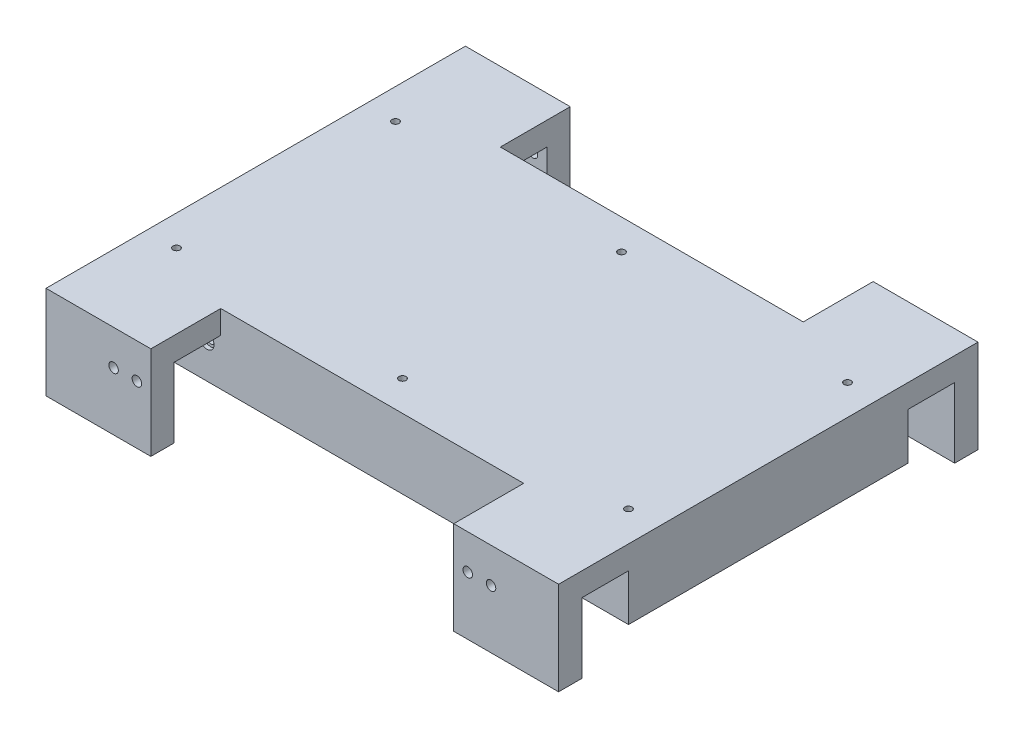
from build123d import *

# Parameters (mm, degrees)
SKETCH1_W                                      = 279.4
SKETCH1_H                                      = 152.4
SKETCH1_W_2                                    = 254
SKETCH1_H_2                                    = 127
EXTRUDE_THIN1_DEPTH                            = 50.8
SKETCH2_W                                      = 279.4
SKETCH2_H                                      = 152.4
BOSS_EXTRUDE2_DEPTH                            = 6.35
SKETCH13_W                                     = 64.77
SKETCH13_H                                     = 25.4
BOSS_EXTRUDE3_DEPTH                            = 31.75
BRAIN_SCREW_D                                  = 3.7973
BRAIN_SCREW_CBORE_D                            = 7.14502
BRAIN_SCREW_CBORE_DEPTH                        = 3.5052
SKETCH18_W                                     = 57.15
SKETCH18_H                                     = 50.8
AXEL_MOUNT_DEPTH                               = 38.1
SKETCH16_R                                     = 2.286
AXEL_THROUGH_DEPTH                             = 114.3
BRAN_SCREW_MIRROR_2_COPY_1_D                   = 3.7973
BRAN_SCREW_MIRROR_2_COPY_1_CBORE_D             = 7.14502
BRAN_SCREW_MIRROR_2_COPY_1_CBORE_DEPTH         = 3.5052
CBORE_FOR_6_SOCKET_HEAD_CAP_SCREW2_D           = 3.7973
CBORE_FOR_6_SOCKET_HEAD_CAP_SCREW2_CBORE_D     = 7.14502
CBORE_FOR_6_SOCKET_HEAD_CAP_SCREW2_CBORE_DEPTH = 3.5052
SKETCH19_W                                     = 25.4
SKETCH19_H                                     = 38.1
AXEL_CUTOUT_DEPTH                              = 303.043257838
MIRROR17_COPY_1_SKETCH_R                       = 2.286
MIRROR17_COPY_1_DEPTH                          = 114.3
MIRROR2_COPY_1_SKETCH_W                        = 57.15
MIRROR2_COPY_1_SKETCH_H                        = 50.8
MIRROR2_COPY_1_DEPTH                           = 38.1
MIRROR2_COPY_2_SKETCH_W                        = 25.4
MIRROR2_COPY_2_SKETCH_H                        = 38.1
MIRROR2_COPY_2_DEPTH                           = 303.043257838
SKETCH25_W                                     = 50.8
SKETCH25_H                                     = 25.4
MOTOR_CUTOUT_DEPTH                             = 10.414
SKETCH26_R                                     = 2.286
MOTOR_MOUNT_HOLES_DEPTH                        = 14.986
SKETCH37_W                                     = 2.5908
SKETCH37_H                                     = 50.8
F_6_0_204_DIAMETER_HOLE1_AT_2_COUNT            = 2
F_6_0_204_DIAMETER_HOLE1_AT_2_PITCH            = 12.7
MIRROR14_COPY_1_SKETCH_W                       = 2.5908
MIRROR14_COPY_1_SKETCH_H                       = 50.8
MIRROR15_COPY_1_SKETCH_W                       = 2.5908
MIRROR15_COPY_1_SKETCH_H                       = 50.8
MIRROR15_COPY_2_SKETCH_W                       = 2.5908
MIRROR15_COPY_2_SKETCH_H                       = 50.8
MIRROR15_COPY_3_SKETCH_W                       = 2.5908
MIRROR15_COPY_3_SKETCH_H                       = 50.8
MIRROR6_COPY_1_SKETCH_W                        = 50.8
MIRROR6_COPY_1_SKETCH_H                        = 25.4
MIRROR6_COPY_1_DEPTH                           = 10.414
MIRROR6_COPY_2_SKETCH_R                        = 2.286
MIRROR6_COPY_2_DEPTH                           = 14.986
COUNTERSINKMOTOR_MOUNT_AT_2_COUNT              = 2
COUNTERSINKMOTOR_MOUNT_AT_2_PITCH              = 12.7
SKETCH43_W                                     = 279.4
SKETCH43_H                                     = 152.4
CUT_EXTRUDE3_DEPTH                             = 19.05
AXEL_HOLES_DEPTH                               = 5.08
MIRROR30_COPY_1_DEPTH                          = 5.08


with BuildPart() as part:
    # Sketch1 → Extrude-Thin1 (new body)
    with BuildSketch(Plane(origin=(0, 0, 0), x_dir=(1, 0, 0), z_dir=(0, 1, 0))):
        with Locations((46.352288391, -14.803029666)):
            Rectangle(SKETCH1_W, SKETCH1_H)
        with Locations((46.352288391, -14.803029666)):
            Rectangle(SKETCH1_W_2, SKETCH1_H_2, mode=Mode.SUBTRACT)
    extrude(amount=EXTRUDE_THIN1_DEPTH)

    # Sketch2 → Boss-Extrude2 (add)
    with BuildSketch(Plane(origin=(0, 50.8, 0), x_dir=(1, 0, 0), z_dir=(0, 1, 0))):
        with Locations((46.352288391, -14.803029666)):
            Rectangle(SKETCH2_W, SKETCH2_H)
    extrude(amount=BOSS_EXTRUDE2_DEPTH)

    # Sketch13 → Boss-Extrude3 (add)
    with BuildSketch(Plane(origin=(0, 50.8, 0), x_dir=(-1, 0, 0), z_dir=(0, -1, 0))):
        with Locations((-140.967288391, -65.603029666)):
            Rectangle(SKETCH13_W, SKETCH13_H)
        with Locations((-140.967288391, 35.996970334)):
            Rectangle(SKETCH13_W, SKETCH13_H)
        with Locations((48.262711609, -65.603029666)):
            Rectangle(SKETCH13_W, SKETCH13_H)
        with Locations((48.262711609, 35.996970334)):
            Rectangle(SKETCH13_W, SKETCH13_H)
    extrude(amount=BOSS_EXTRUDE3_DEPTH)

    # Brain Screw (through all)
    with Locations(Plane(origin=(169.542288391, 19.05, -44.886970334), x_dir=(0, 0, -1), z_dir=(0, -1, 0))):
        with Locations((0, 0)):
            brain_screw = CounterBoreHole(BRAIN_SCREW_D / 2, BRAIN_SCREW_CBORE_D / 2, BRAIN_SCREW_CBORE_DEPTH)

    # Sketch18 → Axel Mount (add)
    with BuildSketch(Plane(origin=(0, 0, -61.396970334), x_dir=(-1, 0, 0), z_dir=(0, 0, -1))):
        with Locations((-157.477288391, 31.75)):
            Rectangle(SKETCH18_W, SKETCH18_H)
    axel_mount = extrude(amount=AXEL_MOUNT_DEPTH)

    # Sketch16 → Axel Through (cut)
    with BuildSketch(Plane(origin=(0, 0, -61.396970334), x_dir=(-1, 0, 0), z_dir=(0, 0, -1))):
        with Locations((-161.922288391, 38.1)):
            Circle(SKETCH16_R)
    axel_through = extrude(amount=-AXEL_THROUGH_DEPTH, mode=Mode.SUBTRACT)

    # Mirror16: Axel Through across plane
    add(axel_through.mirror(Plane.ZY.offset(-46.352288391)), mode=Mode.SUBTRACT)

    # Brain Screw Mirror: Brain Screw across plane
    add(brain_screw.mirror(Plane.ZY.offset(-46.352288391)), mode=Mode.SUBTRACT)

    # Bran Screw Mirror 2: Brain Screw across plane
    add(brain_screw.mirror(Plane.XY.offset(14.803029666)), mode=Mode.SUBTRACT)

    # Bran Screw Mirror 2 copy 1 (through all)
    with Locations(Plane(origin=(-76.837711609, 19.05, 74.493029666), x_dir=(0, 0, 1), z_dir=(0, -1, 0))):
        with Locations((0, 0)):
            CounterBoreHole(BRAN_SCREW_MIRROR_2_COPY_1_D / 2, BRAN_SCREW_MIRROR_2_COPY_1_CBORE_D / 2, BRAN_SCREW_MIRROR_2_COPY_1_CBORE_DEPTH)

    # CBORE for #6 Socket Head Cap Screw2 (through all)
    with Locations(Plane(origin=(46.352288391, 50.8, -44.886970334), x_dir=(0, 0, -1), z_dir=(0, -1, 0))):
        with Locations((0, 0)):
            cbore_for_6_socket_head_cap_screw2 = CounterBoreHole(CBORE_FOR_6_SOCKET_HEAD_CAP_SCREW2_D / 2, CBORE_FOR_6_SOCKET_HEAD_CAP_SCREW2_CBORE_D / 2, CBORE_FOR_6_SOCKET_HEAD_CAP_SCREW2_CBORE_DEPTH)

    # Mirror21: CBORE for #6 Socket Head Cap Screw2 across plane
    add(cbore_for_6_socket_head_cap_screw2.mirror(Plane.XY.offset(14.803029666)), mode=Mode.SUBTRACT)

    # Sketch19 → Axel Cutout (cut, through all)
    with BuildSketch(Plane(origin=(186.052288391, 0, 0), x_dir=(0, 0, -1), z_dir=(1, 0, 0))):
        with Locations((74.096970334, 25.4)):
            Rectangle(SKETCH19_W, SKETCH19_H)
    axel_cutout = extrude(amount=-AXEL_CUTOUT_DEPTH, mode=Mode.SUBTRACT)

    # Mirror17: Axel Through across plane
    add(axel_through.mirror(Plane.XY.offset(14.803029666)), mode=Mode.SUBTRACT)

    # Mirror17 copy 1 sketch → Mirror17 copy 1 (cut)
    with BuildSketch(Plane(origin=(92.704576782, 0, 91.003029666), x_dir=(1, 0, 0), z_dir=(0, 0, 1))):
        with Locations((-161.922288391, 38.1)):
            Circle(MIRROR17_COPY_1_SKETCH_R)
    extrude(amount=-MIRROR17_COPY_1_DEPTH, mode=Mode.SUBTRACT)

    # Mirror1: Axel Mount, Axel Cutout across plane
    add(axel_mount.mirror(Plane.ZY.offset(-46.352288391)))
    add(axel_cutout.mirror(Plane.ZY.offset(-46.352288391)), mode=Mode.SUBTRACT)

    # Mirror2: Axel Mount, Axel Cutout across plane
    add(axel_mount.mirror(Plane.XY.offset(14.803029666)))
    add(axel_cutout.mirror(Plane.XY.offset(14.803029666)), mode=Mode.SUBTRACT)

    # Mirror2 copy 1 sketch → Mirror2 copy 1 (add)
    with BuildSketch(Plane(origin=(92.704576782, 0, 91.003029666), x_dir=(1, 0, 0), z_dir=(0, 0, 1))):
        with Locations((-157.477288391, 31.75)):
            Rectangle(MIRROR2_COPY_1_SKETCH_W, MIRROR2_COPY_1_SKETCH_H)
    extrude(amount=MIRROR2_COPY_1_DEPTH)

    # Mirror2 copy 2 sketch → Mirror2 copy 2 (cut, through all)
    with BuildSketch(Plane(origin=(-93.347711609, 0, 29.606059332), x_dir=(0, 0, 1), z_dir=(-1, 0, 0))):
        with Locations((74.096970334, 25.4)):
            Rectangle(MIRROR2_COPY_2_SKETCH_W, MIRROR2_COPY_2_SKETCH_H)
    extrude(amount=-MIRROR2_COPY_2_DEPTH, mode=Mode.SUBTRACT)

    # Sketch25 → Motor Cutout (cut)
    with BuildSketch(Plane.XY.offset(-23.296970334)):
        with Locations((147.952288391, 38.1)):
            Rectangle(SKETCH25_W, SKETCH25_H)
    motor_cutout = extrude(amount=-MOTOR_CUTOUT_DEPTH, mode=Mode.SUBTRACT)

    # Sketch26 → Motor Mount Holes (cut)
    with BuildSketch(Plane.XY.offset(-33.710970334)):
        with Locations(Location((161.922288391, 38.1, 0), (0, 0, 180))):
            Circle(SKETCH26_R)
        with BuildLine():
            Line((141.99659531, 37.458182422), (141.545948431, 37.458182422))
            ThreePointArc((141.545948431, 37.458182422), (131.458921261, 38.091103702), (141.545948431, 38.724024983))
            Line((141.545948431, 38.724024983), (141.99659531, 38.724024983))
            Line((141.99659531, 38.724024983), (142.038169696, 40.095312833))
            Line((142.038169696, 40.095312833), (143.789562089, 40.095312833))
            Line((143.789562089, 40.095312833), (143.747987703, 38.724024983))
            Line((143.747987703, 38.724024983), (144.198634582, 38.724024983))
            ThreePointArc((144.198634582, 38.724024983), (154.285661752, 38.091103702), (144.198634582, 37.458182422))
            Line((144.198634582, 37.458182422), (143.747987703, 37.458182422))
            Line((143.747987703, 37.458182422), (143.706413317, 36.086894572))
            Line((143.706413317, 36.086894572), (141.955020924, 36.086894572))
            Line((141.955020924, 36.086894572), (141.99659531, 37.458182422))
        make_face()
    motor_mount_holes = extrude(amount=-MOTOR_MOUNT_HOLES_DEPTH, mode=Mode.SUBTRACT)

    # Sketch37 → #6 (0.204) Diameter Hole1 (revolve, cut)
    with BuildSketch(Plane(origin=(149.222291507, 38.091103702, -48.696970334), x_dir=(0, -1, 0), z_dir=(1, 0, 0))):
        with Locations((1.2954, 25.4)):
            Rectangle(SKETCH37_W, SKETCH37_H)
    f_6_0_204_diameter_hole1 = revolve(axis=Axis((149.222291507, 38.091103702, -42.346970334), (0, 0, -1)), mode=Mode.SUBTRACT)

    # #6 (0.204) Diameter Hole1 at 2: #6 (0.204) Diameter Hole1 ×2
    with Locations(*[(-i * F_6_0_204_DIAMETER_HOLE1_AT_2_PITCH, 0, 0) for i in range(1, F_6_0_204_DIAMETER_HOLE1_AT_2_COUNT)]):
        add(f_6_0_204_diameter_hole1, mode=Mode.SUBTRACT)

    # Mirror14: #6 (0.204) Diameter Hole1 across plane
    add(f_6_0_204_diameter_hole1.mirror(Plane.ZY.offset(-46.352288391)), mode=Mode.SUBTRACT)

    # Mirror14 copy 1 sketch → Mirror14 copy 1 (revolve, cut)
    with BuildSketch(Plane(origin=(-43.817714725, 38.091103702, -48.696970334), x_dir=(0, -1, 0), z_dir=(-1, 0, 0))):
        with Locations((1.2954, -25.4)):
            Rectangle(MIRROR14_COPY_1_SKETCH_W, MIRROR14_COPY_1_SKETCH_H)
    revolve(axis=Axis((-43.817714725, 38.091103702, -42.346970334), (0, 0, 1)), mode=Mode.SUBTRACT)

    # Mirror15: #6 (0.204) Diameter Hole1 across plane
    add(f_6_0_204_diameter_hole1.mirror(Plane.XY.offset(14.803029666)), mode=Mode.SUBTRACT)

    # Mirror15 copy 1 sketch → Mirror15 copy 1 (revolve, cut)
    with BuildSketch(Plane(origin=(136.522291507, 38.091103702, 78.303029666), x_dir=(0, -1, 0), z_dir=(1, 0, 0))):
        with Locations((1.2954, -25.4)):
            Rectangle(MIRROR15_COPY_1_SKETCH_W, MIRROR15_COPY_1_SKETCH_H)
    revolve(axis=Axis((136.522291507, 38.091103702, 71.953029666), (0, 0, -1)), mode=Mode.SUBTRACT)

    # Mirror15 copy 2 sketch → Mirror15 copy 2 (revolve, cut)
    with BuildSketch(Plane(origin=(-56.517714725, 38.091103702, 78.303029666), x_dir=(0, -1, 0), z_dir=(-1, 0, 0))):
        with Locations((1.2954, 25.4)):
            Rectangle(MIRROR15_COPY_2_SKETCH_W, MIRROR15_COPY_2_SKETCH_H)
    revolve(axis=Axis((-56.517714725, 38.091103702, 71.953029666), (0, 0, 1)), mode=Mode.SUBTRACT)

    # Mirror15 copy 3 sketch → Mirror15 copy 3 (revolve, cut)
    with BuildSketch(Plane(origin=(-43.817714725, 38.091103702, 78.303029666), x_dir=(0, -1, 0), z_dir=(-1, 0, 0))):
        with Locations((1.2954, 25.4)):
            Rectangle(MIRROR15_COPY_3_SKETCH_W, MIRROR15_COPY_3_SKETCH_H)
    revolve(axis=Axis((-43.817714725, 38.091103702, 71.953029666), (0, 0, 1)), mode=Mode.SUBTRACT)

    # Motor Cutout Mirror: Motor Cutout, Motor Mount Holes across plane
    add(motor_cutout.mirror(Plane.XY.offset(14.803029666)), mode=Mode.SUBTRACT)
    add(motor_mount_holes.mirror(Plane.XY.offset(14.803029666)), mode=Mode.SUBTRACT)

    # Mirror6: Motor Cutout, Motor Mount Holes across plane
    add(motor_cutout.mirror(Plane.ZY.offset(-46.352288391)), mode=Mode.SUBTRACT)
    add(motor_mount_holes.mirror(Plane.ZY.offset(-46.352288391)), mode=Mode.SUBTRACT)

    # Mirror6 copy 1 sketch → Mirror6 copy 1 (cut)
    with BuildSketch(Plane(origin=(92.704576782, 0, 52.903029666), x_dir=(-1, 0, 0), z_dir=(0, 0, -1))):
        with Locations((147.952288391, 38.1)):
            Rectangle(MIRROR6_COPY_1_SKETCH_W, MIRROR6_COPY_1_SKETCH_H)
    extrude(amount=-MIRROR6_COPY_1_DEPTH, mode=Mode.SUBTRACT)

    # Mirror6 copy 2 sketch → Mirror6 copy 2 (cut)
    with BuildSketch(Plane(origin=(92.704576782, 0, 63.317029666), x_dir=(-1, 0, 0), z_dir=(0, 0, -1))):
        with Locations(Location((161.922288391, 38.1, 0), (0, 0, 180))):
            Circle(MIRROR6_COPY_2_SKETCH_R)
        with BuildLine():
            Line((141.99659531, 37.458182422), (141.545948431, 37.458182422))
            ThreePointArc((141.545948431, 37.458182422), (131.458921261, 38.091103702), (141.545948431, 38.724024983))
            Line((141.545948431, 38.724024983), (141.99659531, 38.724024983))
            Line((141.99659531, 38.724024983), (142.038169696, 40.095312833))
            Line((142.038169696, 40.095312833), (143.789562089, 40.095312833))
            Line((143.789562089, 40.095312833), (143.747987703, 38.724024983))
            Line((143.747987703, 38.724024983), (144.198634582, 38.724024983))
            ThreePointArc((144.198634582, 38.724024983), (154.285661752, 38.091103702), (144.198634582, 37.458182422))
            Line((144.198634582, 37.458182422), (143.747987703, 37.458182422))
            Line((143.747987703, 37.458182422), (143.706413317, 36.086894572))
            Line((143.706413317, 36.086894572), (141.955020924, 36.086894572))
            Line((141.955020924, 36.086894572), (141.99659531, 37.458182422))
        make_face()
    extrude(amount=-MIRROR6_COPY_2_DEPTH, mode=Mode.SUBTRACT)

    # Sketch31 → CounterSinkMotor Mount (revolve, cut)
    with BuildSketch(Plane(origin=(136.522291507, 38.091103702, -61.396970334), x_dir=(0, 1, 0), z_dir=(1, 0, 0))):
        Polygon((0, 0), (0, 190.5), (1.89865, 190.5), (1.89865, 2.2098), (3.96875, 2.2098), (3.96875, 0), align=None)
    countersinkmotor_mount = revolve(axis=Axis((136.522291507, 38.091103702, -67.746970334), (0, 0, 1)), mode=Mode.SUBTRACT)

    # CounterSinkMotor Mount at 2: CounterSinkMotor Mount ×2
    with Locations(*[(i * COUNTERSINKMOTOR_MOUNT_AT_2_PITCH, 0, 0) for i in range(1, COUNTERSINKMOTOR_MOUNT_AT_2_COUNT)]):
        add(countersinkmotor_mount, mode=Mode.SUBTRACT)

    # Mirror9: CounterSinkMotor Mount across plane
    add(countersinkmotor_mount.mirror(Plane.XY.offset(14.803029666)), mode=Mode.SUBTRACT)

    # Mirror9 copy 1 sketch → Mirror9 copy 1 (revolve, cut)
    with BuildSketch(Plane(origin=(149.222291507, 38.091103702, 91.003029666), x_dir=(0, 1, 0), z_dir=(1, 0, 0))):
        Polygon((0, 0), (0, -190.5), (1.89865, -190.5), (1.89865, -2.2098), (3.96875, -2.2098), (3.96875, 0), align=None)
    revolve(axis=Axis((149.222291507, 38.091103702, 97.353029666), (0, 0, 1)), mode=Mode.SUBTRACT)

    # Mirror10: CounterSinkMotor Mount across plane
    add(countersinkmotor_mount.mirror(Plane.ZY.offset(-46.352288391)), mode=Mode.SUBTRACT)

    # Mirror10 copy 1 sketch → Mirror10 copy 1 (revolve, cut)
    with BuildSketch(Plane(origin=(-56.517714725, 38.091103702, -61.396970334), x_dir=(0, 1, 0), z_dir=(-1, 0, 0))):
        Polygon((0, 0), (0, -190.5), (1.89865, -190.5), (1.89865, -2.2098), (3.96875, -2.2098), (3.96875, 0), align=None)
    revolve(axis=Axis((-56.517714725, 38.091103702, -67.746970334), (0, 0, -1)), mode=Mode.SUBTRACT)

    # Mirror10 copy 2 sketch → Mirror10 copy 2 (revolve, cut)
    with BuildSketch(Plane(origin=(-43.817714725, 38.091103702, 91.003029666), x_dir=(0, 1, 0), z_dir=(-1, 0, 0))):
        Polygon((0, 0), (0, 190.5), (1.89865, 190.5), (1.89865, 2.2098), (3.96875, 2.2098), (3.96875, 0), align=None)
    revolve(axis=Axis((-43.817714725, 38.091103702, 97.353029666), (0, 0, -1)), mode=Mode.SUBTRACT)

    # Mirror10 copy 3 sketch → Mirror10 copy 3 (revolve, cut)
    with BuildSketch(Plane(origin=(-56.517714725, 38.091103702, 91.003029666), x_dir=(0, 1, 0), z_dir=(-1, 0, 0))):
        Polygon((0, 0), (0, 190.5), (1.89865, 190.5), (1.89865, 2.2098), (3.96875, 2.2098), (3.96875, 0), align=None)
    revolve(axis=Axis((-56.517714725, 38.091103702, 97.353029666), (0, 0, -1)), mode=Mode.SUBTRACT)

    # Sketch43 → Cut-Extrude3 (cut)
    with BuildSketch(Plane.XZ):
        with Locations((46.352288391, 14.803029666)):
            Rectangle(SKETCH43_W, SKETCH43_H)
    extrude(amount=-CUT_EXTRUDE3_DEPTH, mode=Mode.SUBTRACT)

    # Sketch44 → Axel Holes (cut)
    with BuildSketch(Plane.XY.offset(-86.796970334)):
        with BuildLine():
            Line((-64.869009253, 40.96385), (-50.899009253, 19.750667778))
            ThreePointArc((-50.899009253, 19.750667778), (-52.383861609, 12.538115422), (-59.596413965, 14.022967778))
            Line((-59.596413965, 14.022967778), (-73.566413965, 35.23615))
            ThreePointArc((-73.566413965, 35.23615), (-72.081561609, 42.448702356), (-64.869009253, 40.96385))
        make_face()
    axel_holes = extrude(amount=-AXEL_HOLES_DEPTH, mode=Mode.SUBTRACT)

    # Mirror29: Axel Holes across plane
    add(axel_holes.mirror(Plane.ZY.offset(-46.352288391)), mode=Mode.SUBTRACT)

    # Mirror30: Axel Holes across plane
    add(axel_holes.mirror(Plane.XY.offset(14.803029666)), mode=Mode.SUBTRACT)

    # Mirror30 copy 1 sketch → Mirror30 copy 1 (cut)
    with BuildSketch(Plane(origin=(92.704576782, 0, 116.403029666), x_dir=(-1, 0, 0), z_dir=(0, 0, -1))):
        with BuildLine():
            Line((-64.869009253, 40.96385), (-50.899009253, 19.750667778))
            ThreePointArc((-50.899009253, 19.750667778), (-52.383861609, 12.538115422), (-59.596413965, 14.022967778))
            Line((-59.596413965, 14.022967778), (-73.566413965, 35.23615))
            ThreePointArc((-73.566413965, 35.23615), (-72.081561609, 42.448702356), (-64.869009253, 40.96385))
        make_face()
    extrude(amount=-MIRROR30_COPY_1_DEPTH, mode=Mode.SUBTRACT)


solid = part.part
